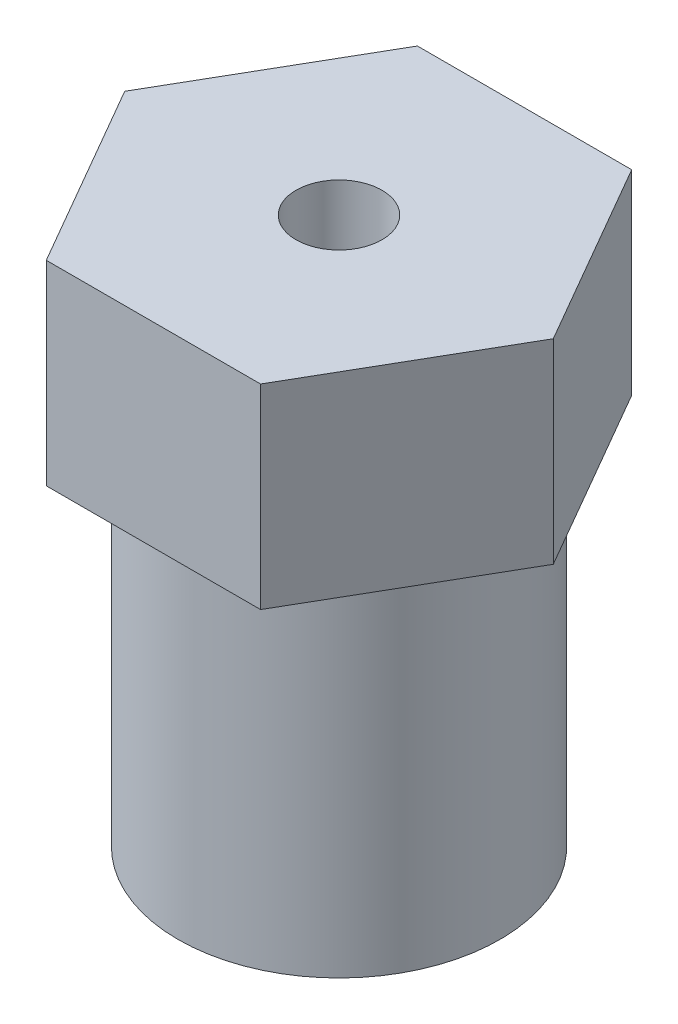
from build123d import *

# Parameters (mm, degrees)
SKETCH1_R           = 5.2324
BOSS_EXTRUDE1_DEPTH = 11.43
BOSS_EXTRUDE2_DEPTH = 6.35
SKETCH3_R           = 1.397
CUT_EXTRUDE1_DEPTH  = 18.78


with BuildPart() as part:
    # Sketch1 → Boss-Extrude1 (new body)
    with BuildSketch(Plane(origin=(0, 0, 0), x_dir=(1, 0, 0), z_dir=(0, 1, 0))):
        Circle(SKETCH1_R)
    extrude(amount=BOSS_EXTRUDE1_DEPTH)

    # Sketch2 → Boss-Extrude2 (add)
    with BuildSketch(Plane(origin=(0, 11.43, 0), x_dir=(1, 0, 0), z_dir=(0, 1, 0))):
        Polygon((6.965730998, 0), (3.482865499, 6.0325), (-3.482865499, 6.0325), (-6.965730998, 0), (-3.482865499, -6.0325), (3.482865499, -6.0325), align=None)
    extrude(amount=BOSS_EXTRUDE2_DEPTH)

    # Sketch3 → Cut-Extrude1 (cut, through all)
    with BuildSketch(Plane(origin=(0, 17.78, 0), x_dir=(1, 0, 0), z_dir=(0, 1, 0))):
        Circle(SKETCH3_R)
    extrude(amount=-CUT_EXTRUDE1_DEPTH, mode=Mode.SUBTRACT)


solid = part.part
